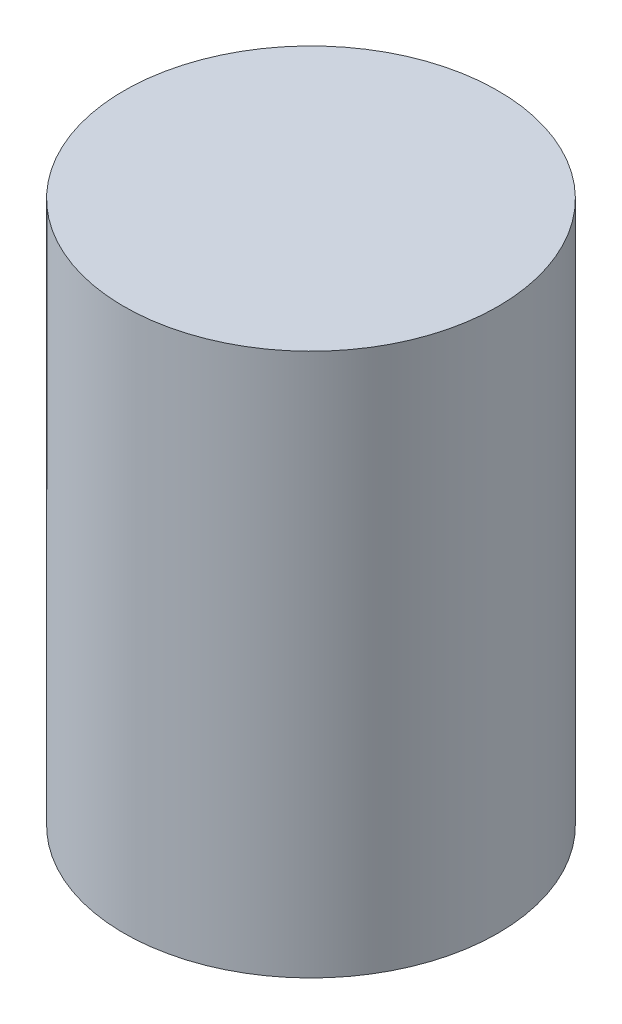
from build123d import *

# Parameters (mm, degrees)
SKETCH3_W   = 25
SKETCH3_H   = 20
SKETCH3_W_2 = 10
SKETCH3_H_2 = 71.6
SKETCH3_H_3 = 10


with BuildPart() as part:
    # Sketch3 → Revolve2 (revolve)
    with BuildSketch(Plane.XY):
        with Locations((12.5, 10)):
            Rectangle(SKETCH3_W, SKETCH3_H)
        with Locations((30, 10)):
            Rectangle(SKETCH3_W_2, SKETCH3_H)
        with Locations((30, 55.8)):
            Rectangle(SKETCH3_W_2, SKETCH3_H_2)
        with Locations((30, 96.6)):
            Rectangle(SKETCH3_W_2, SKETCH3_H_3)
        with Locations((12.5, 96.6)):
            Rectangle(SKETCH3_W, SKETCH3_H_3)
    revolve(axis=Axis((0, -32.020016396, 0), (0, 1, 0)))


solid = part.part
